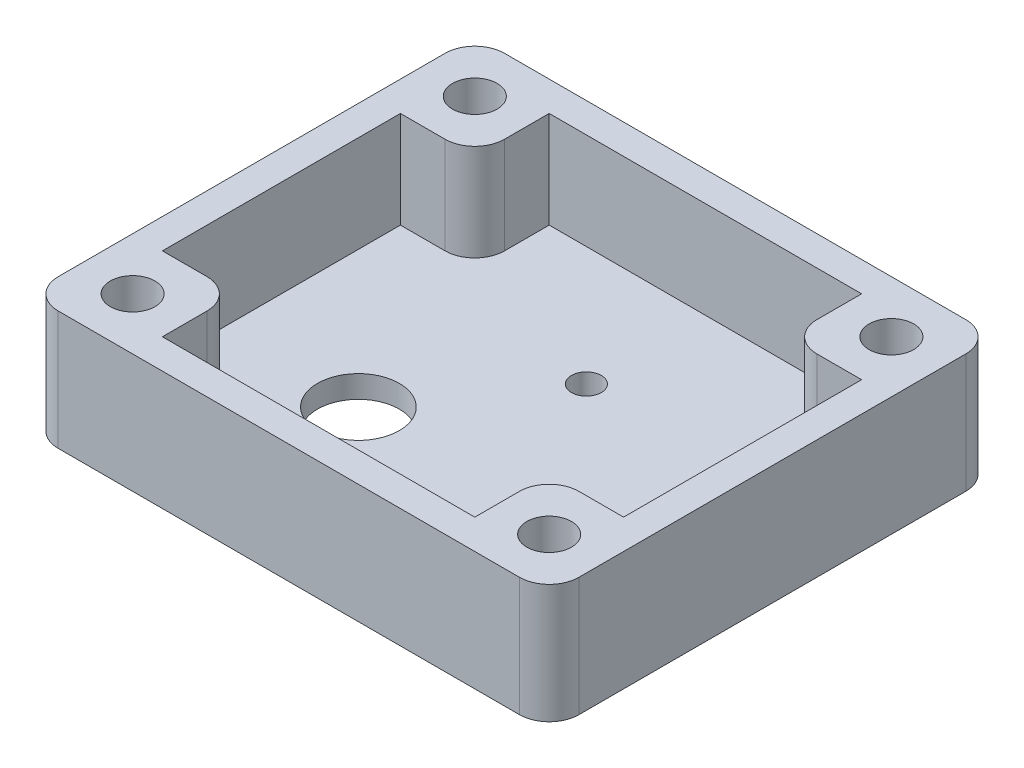
from build123d import *

# Parameters (mm, degrees)
SKETCH1_W           = 35
SKETCH1_H           = 30
SKETCH1_R           = 2.75
SKETCH1_R_2         = 1
BOSS_EXTRUDE1_DEPTH = 1.5
SKETCH2_W           = 35
SKETCH2_H           = 30
BOSS_EXTRUDE2_DEPTH = 6.5
SKETCH3_R           = 1.5
CUT_EXTRUDE1_DEPTH  = 9
FILLET1_R           = 2


with BuildPart() as part:
    # Sketch1 → Boss-Extrude1 (new body)
    with BuildSketch(Plane(origin=(0, 0, 0), x_dir=(1, 0, 0), z_dir=(0, 1, 0))):
        Rectangle(SKETCH1_W, SKETCH1_H)
        with Locations((-6.32455, -4)):
            Circle(SKETCH1_R, mode=Mode.SUBTRACT)
        with Locations((0, 5)):
            Circle(SKETCH1_R_2, mode=Mode.SUBTRACT)
    extrude(amount=BOSS_EXTRUDE1_DEPTH)

    # Sketch2 → Boss-Extrude2 (add)
    with BuildSketch(Plane(origin=(0, 1.5, 0), x_dir=(1, 0, 0), z_dir=(0, 1, 0))):
        Rectangle(SKETCH2_W, SKETCH2_H)
        Polygon((-10.5, 13), (10.5, 13), (10.5, 8), (15.5, 8), (15.5, -8), (10.5, -8), (10.5, -13), (-10.5, -13), (-10.5, -8), (-15.5, -8), (-15.5, 8), (-10.5, 8), align=None, mode=Mode.SUBTRACT)
    extrude(amount=BOSS_EXTRUDE2_DEPTH)

    # Sketch3 → Cut-Extrude1 (cut, through all)
    with BuildSketch(Plane(origin=(0, 8, 0), x_dir=(1, 0, 0), z_dir=(0, 1, 0))):
        with Locations((-14, 11.5)):
            Circle(SKETCH3_R)
        with Locations((-14, -11.5)):
            Circle(SKETCH3_R)
        with Locations((14, -11.5)):
            Circle(SKETCH3_R)
        with Locations((14, 11.5)):
            Circle(SKETCH3_R)
    extrude(amount=-CUT_EXTRUDE1_DEPTH, mode=Mode.SUBTRACT)

    # Fillet1
    fillet1_edges = [part.edges().sort_by_distance(p)[0] for p in [
        (-10.5, 4.75, -8),
        (-10.5, 4.75, 8),
        (10.5, 4.75, 8),
        (10.5, 4.75, -8),
        (17.5, 4, 15),
        (-17.5, 4, 15),
        (-17.5, 4, -15),
        (17.5, 4, -15),
    ]]
    fillet(fillet1_edges, radius=FILLET1_R)


solid = part.part
